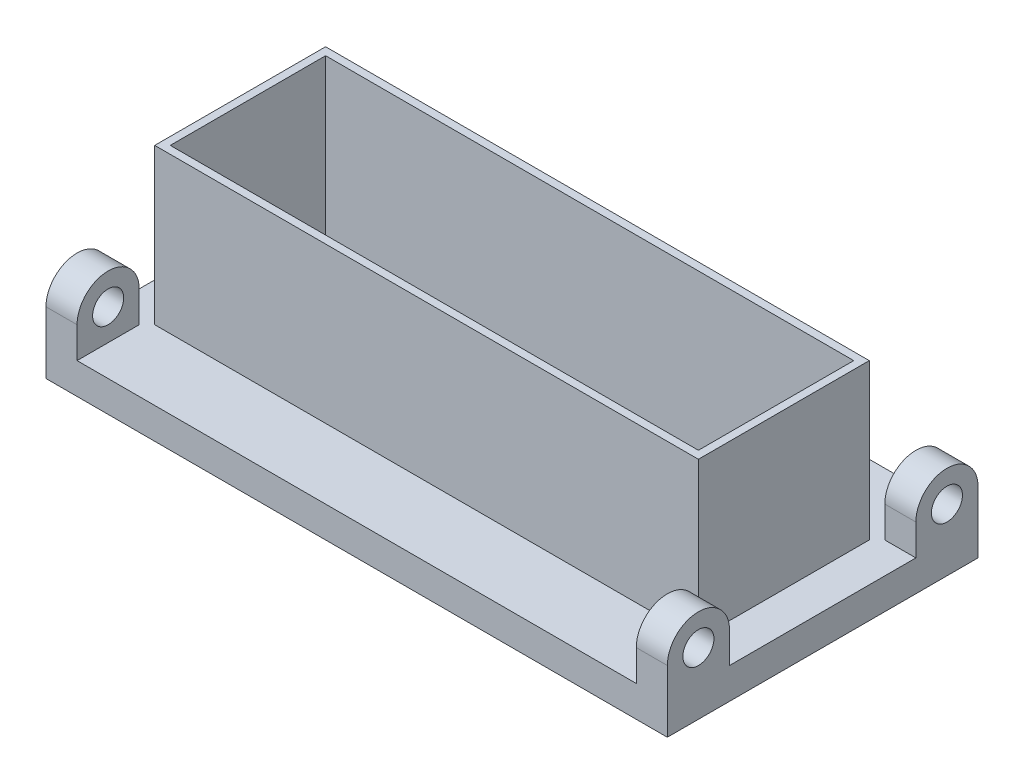
from build123d import *

# Parameters (mm, degrees)
SKETCH1_W                 = 100
SKETCH1_H                 = 10
BOSS_EXTRUDE1_DEPTH       = 100
SKETCH2_R                 = 10
SKETCH2_R_2               = 5
BOSS_EXTRUDE2_DEPTH       = 10
MIRROR2_COPY_1_SKETCH_R   = 10
MIRROR2_COPY_1_SKETCH_R_2 = 5
MIRROR2_COPY_1_DEPTH      = 10
SKETCH3_W                 = 175
SKETCH3_H                 = 55
SKETCH3_W_2               = 170
SKETCH3_H_2               = 50
BOSS_EXTRUDE5_DEPTH       = 50


with BuildPart() as part:
    # Sketch1 → Boss-Extrude1 (new body, symmetric)
    with BuildSketch(Plane(origin=(0, 0, 0), x_dir=(0, 0, -1), z_dir=(1, 0, 0))):
        Rectangle(SKETCH1_W, SKETCH1_H)
    extrude(amount=BOSS_EXTRUDE1_DEPTH, both=True)

    # Sketch2 → Boss-Extrude2 (add)
    with BuildSketch(Plane(origin=(100, 0, 0), x_dir=(0, 0, -1), z_dir=(1, 0, 0))):
        with Locations((-40, 15)):
            Circle(SKETCH2_R)
        with Locations((-40, 15)):
            Circle(SKETCH2_R_2, mode=Mode.SUBTRACT)
        with BuildLine():
            ThreePointArc((-40, 5), (-47.071067812, 7.928932188), (-50, 15))
            Line((-50, 15), (-50, 5))
            Line((-50, 5), (-40, 5))
        make_face()
        with BuildLine():
            Line((-30, 5), (-30, 15))
            ThreePointArc((-30, 15), (-32.928932188, 7.928932188), (-40, 5))
            Line((-40, 5), (-30, 5))
        make_face()
    boss_extrude2 = extrude(amount=-BOSS_EXTRUDE2_DEPTH)

    # Mirror1: Boss-Extrude2 across plane
    add(boss_extrude2.mirror(Plane.XY))

    # Mirror2: Boss-Extrude2 across plane
    add(boss_extrude2.mirror(Plane(origin=(0, 0, 0), x_dir=(0, 0, 1), z_dir=(1, 0, 0))))

    # Mirror2 copy 1 sketch → Mirror2 copy 1 (add)
    with BuildSketch(Plane.ZY.offset(100)):
        with Locations((-40, 15)):
            Circle(MIRROR2_COPY_1_SKETCH_R)
        with Locations((-40, 15)):
            Circle(MIRROR2_COPY_1_SKETCH_R_2, mode=Mode.SUBTRACT)
        with BuildLine():
            ThreePointArc((-40, 5), (-47.071067812, 7.928932188), (-50, 15))
            Line((-50, 15), (-50, 5))
            Line((-50, 5), (-40, 5))
        make_face()
        with BuildLine():
            Line((-30, 5), (-30, 15))
            ThreePointArc((-30, 15), (-32.928932188, 7.928932188), (-40, 5))
            Line((-40, 5), (-30, 5))
        make_face()
    extrude(amount=-MIRROR2_COPY_1_DEPTH)

    # Sketch3 → Boss-Extrude5 (add)
    with BuildSketch(Plane(origin=(0, 5, 0), x_dir=(1, 0, 0), z_dir=(0, 1, 0))):
        Rectangle(SKETCH3_W, SKETCH3_H)
        Rectangle(SKETCH3_W_2, SKETCH3_H_2, mode=Mode.SUBTRACT)
    extrude(amount=BOSS_EXTRUDE5_DEPTH)


solid = part.part
